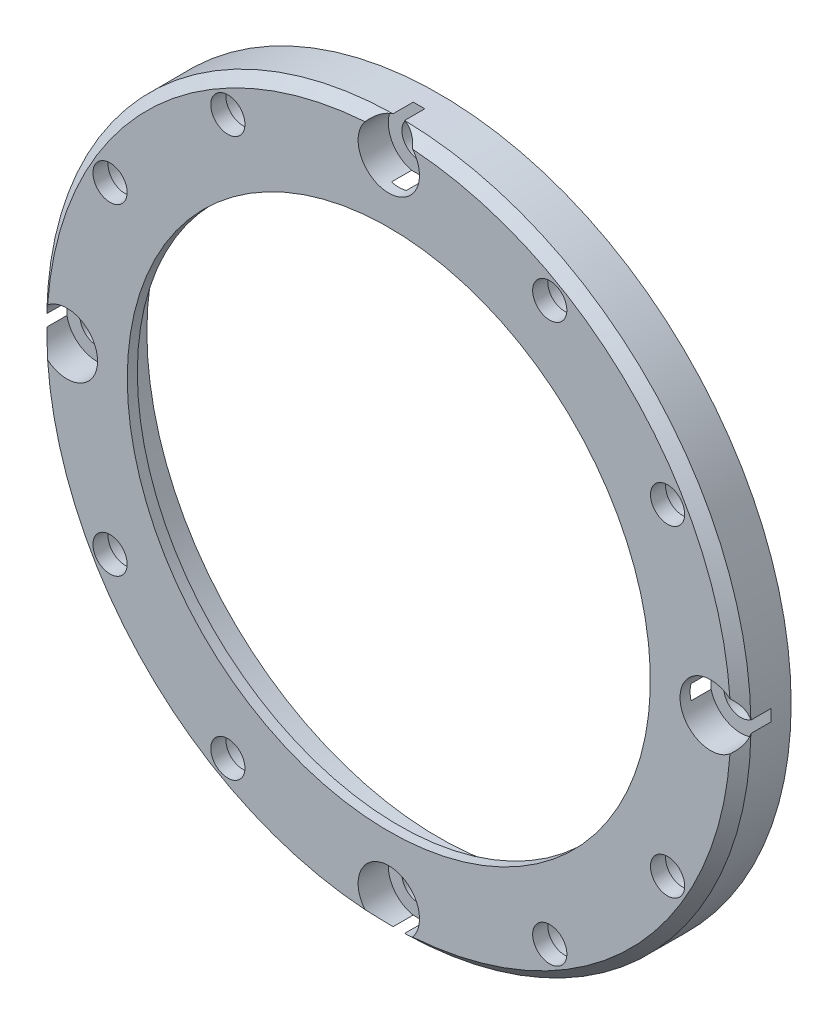
from build123d import *

# Parameters (mm, degrees)
SKETCH_1_W                = 35
SKETCH_1_H                = 5
HOLE_WIZARD_1_D           = 3.4
HOLE_WIZARD_1_DEPTH       = 5
HOLE_WIZARD_2_D           = 52
HOLE_WIZARD_2_DEPTH       = 5
HOLE_WIZARD_2_CBORE_D     = 58.1
HOLE_WIZARD_2_CBORE_DEPTH = 4
HOLE_WIZARD_3_D           = 3.4
HOLE_WIZARD_3_DEPTH       = 5
HOLE_WIZARD_3_CBORE_D     = 6.1
HOLE_WIZARD_3_CBORE_DEPTH = 3
CHAMFER_1_SIZE            = 1
SKETCH_8_R                = 2.2
CUT_EXTRUDE_1_DEPTH       = 3.5


with BuildPart() as part:
    # 草图1 → 旋转1 (revolve)
    with BuildSketch(Plane(origin=(0, 0, 0), x_dir=(1, 0, 0), z_dir=(0, 1, 0))):
        with Locations((17.5, 2.5)):
            Rectangle(SKETCH_1_W, SKETCH_1_H)
    revolve(axis=Axis((0, 0, -5), (0, 0, 1)))

    # 孔1
    with Locations(Plane(origin=(0, 0, -5), x_dir=(-1, 0, 0), z_dir=(0, 0, -1))):
        with Locations((16, -27.712812921), (-16, -27.712812921), (-27.712812921, -16), (-27.712812921, 16), (-16, 27.712812921), (16, 27.712812921), (27.712812921, 16), (27.712812921, -16)):
            Hole(HOLE_WIZARD_1_D / 2, depth=HOLE_WIZARD_1_DEPTH)

    # 孔2
    with Locations(Plane(origin=(0, 0, -5), x_dir=(-1, 0, 0), z_dir=(0, 0, -1))):
        with Locations((0, 0)):
            CounterBoreHole(HOLE_WIZARD_2_D / 2, HOLE_WIZARD_2_CBORE_D / 2, HOLE_WIZARD_2_CBORE_DEPTH, depth=HOLE_WIZARD_2_DEPTH)

    # 孔3
    with Locations(Plane.XY):
        with Locations((0, -32), (0, 32), (-32, 0), (32, 0)):
            CounterBoreHole(HOLE_WIZARD_3_D / 2, HOLE_WIZARD_3_CBORE_D / 2, HOLE_WIZARD_3_CBORE_DEPTH, depth=HOLE_WIZARD_3_DEPTH)

    # 倒角1
    chamfer_1_edges = [part.edges().sort_by_distance(p)[0] for p in [
        (-24.748737342, 24.748737342, 0),
        (24.748737342, -24.748737342, 0),
        (24.748737342, 24.748737342, 0),
        (-24.748737342, -24.748737342, 0),
    ]]
    chamfer(chamfer_1_edges, length=CHAMFER_1_SIZE)

    # 草图8 → 切除-拉伸1 (cut)
    with BuildSketch(Plane(origin=(0, 0, -5), x_dir=(-1, 0, 0), z_dir=(0, 0, -1))):
        with Locations((-27.712812921, 16)):
            Circle(SKETCH_8_R)
        with Locations((-16, 27.712812921)):
            Circle(SKETCH_8_R)
        with Locations((16, 27.712812921)):
            Circle(SKETCH_8_R)
        with Locations((27.712812921, 16)):
            Circle(SKETCH_8_R)
        with Locations((27.712812921, -16)):
            Circle(SKETCH_8_R)
        with Locations((16, -27.712812921)):
            Circle(SKETCH_8_R)
        with Locations((-16, -27.712812921)):
            Circle(SKETCH_8_R)
        with Locations((-27.712812921, -16)):
            Circle(SKETCH_8_R)
    extrude(amount=-CUT_EXTRUDE_1_DEPTH, mode=Mode.SUBTRACT)


solid = part.part
